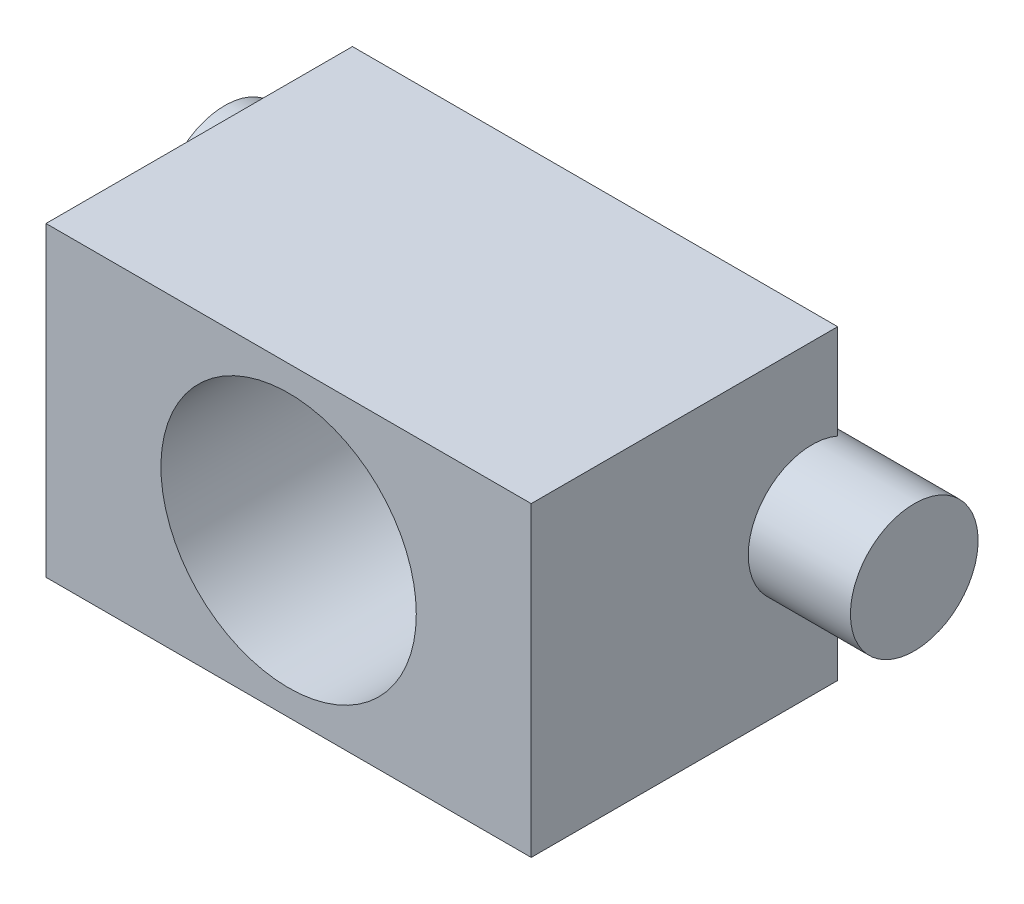
from build123d import *

# Parameters (mm, degrees)
SKETCH1_W                = 95
SKETCH1_H                = 60
SKETCH1_R                = 25
BOSS_EXTRUDE1_DEPTH      = 60
SKETCH2_R                = 12.5
BOSS_EXTRUDE2_DEPTH      = 20
BOSS_EXTRUDE2_DEPTH_BACK = 115


with BuildPart() as part:
    # Sketch1 → Boss-Extrude1 (new body)
    with BuildSketch(Plane.XY):
        with Locations((47.5, 30)):
            Rectangle(SKETCH1_W, SKETCH1_H)
        with Locations((47.5, 30)):
            Circle(SKETCH1_R, mode=Mode.SUBTRACT)
    extrude(amount=BOSS_EXTRUDE1_DEPTH)

    # Sketch2 → Boss-Extrude2 (add, two sides)
    with BuildSketch(Plane.ZY) as boss_extrude2_sk:
        with Locations((5, 30)):
            Circle(SKETCH2_R)
    extrude(amount=BOSS_EXTRUDE2_DEPTH)
    extrude(boss_extrude2_sk.sketch, amount=-BOSS_EXTRUDE2_DEPTH_BACK)


solid = part.part
